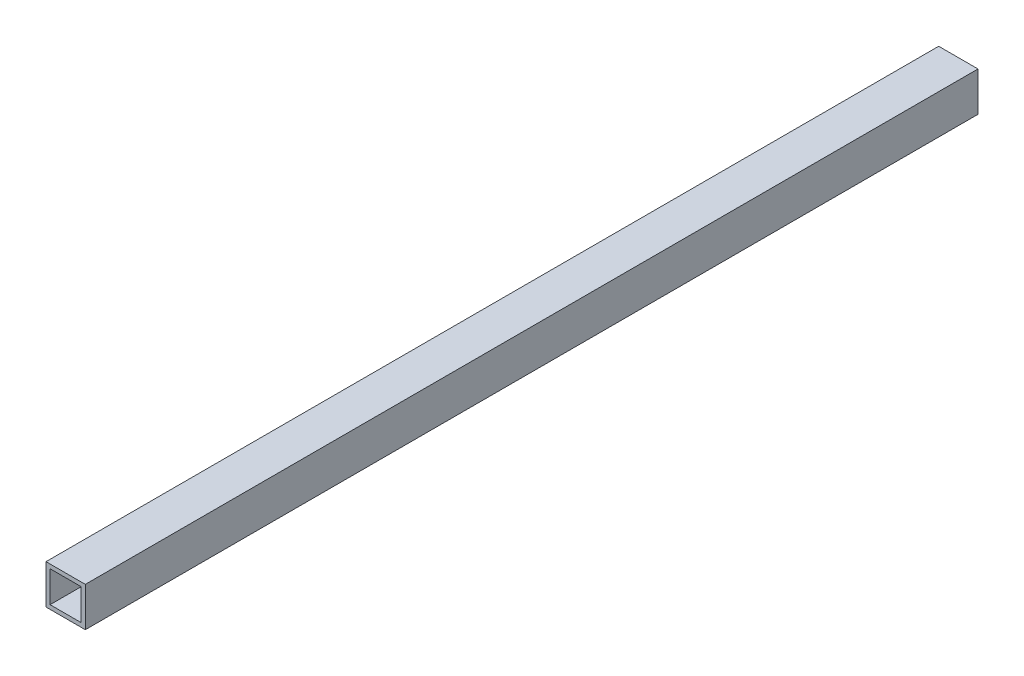
from build123d import *

# Parameters (mm, degrees)
SKETCH_1_W      = 24
SKETCH_1_H      = 24
SKETCH_1_W_2    = 19
SKETCH_1_H_2    = 19
EXTRUDE_1_DEPTH = 545


with BuildPart() as part:
    # 草图1 → 凸台-拉伸1 (new body)
    with BuildSketch(Plane.XY):
        with Locations((12, 12)):
            Rectangle(SKETCH_1_W, SKETCH_1_H)
        with Locations((12, 12)):
            Rectangle(SKETCH_1_W_2, SKETCH_1_H_2, mode=Mode.SUBTRACT)
    extrude(amount=EXTRUDE_1_DEPTH)


solid = part.part
